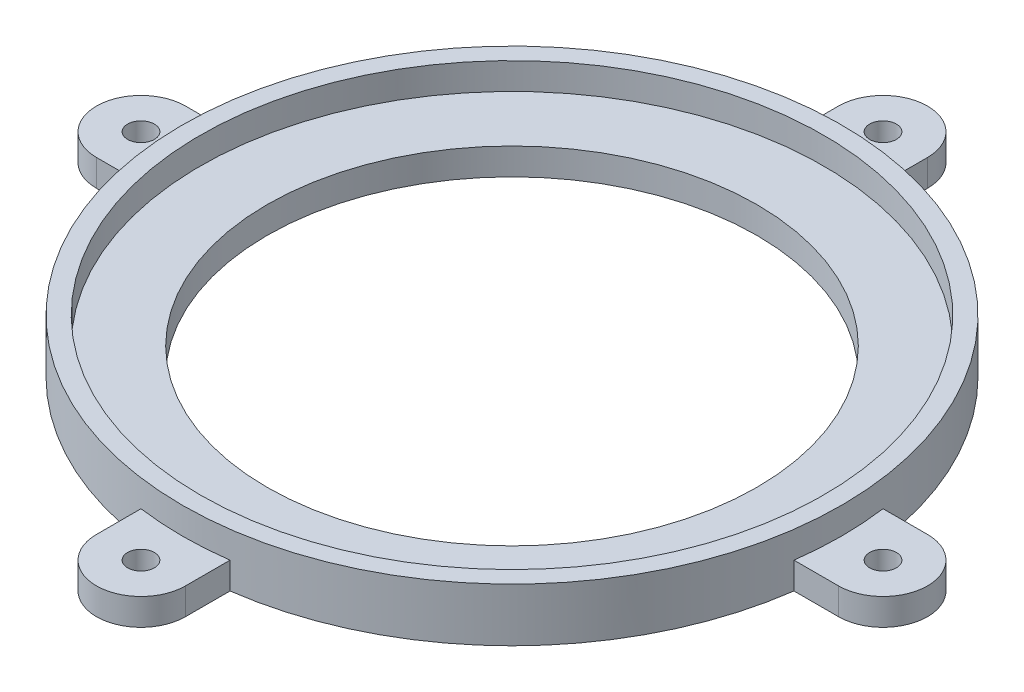
from build123d import *

# Parameters (mm, degrees)
SKETCH1_R           = 1.905
BOSS_EXTRUDE1_DEPTH = 3.81
SKETCH2_R           = 34.925
CUT_EXTRUDE2_DEPTH  = 4.81
SKETCH3_R           = 46.99
SKETCH3_R_2         = 44.45
BOSS_EXTRUDE2_DEPTH = 3.81


with BuildPart() as part:
    # Sketch1 → Boss-Extrude1 (new body)
    with BuildSketch(Plane(origin=(0, 0, 0), x_dir=(1, 0, 0), z_dir=(0, 1, 0))):
        with BuildLine():
            Line((46.558969061, 6.35), (52.908969061, 6.35))
            ThreePointArc((52.908969061, 6.35), (59.258969061, 0), (52.908969061, -6.35))
            Line((52.908969061, -6.35), (46.558969061, -6.35))
            ThreePointArc((46.558969061, -6.35), (33.226947648, -33.226947648), (6.35, -46.558969061))
            Line((6.35, -46.558969061), (6.35, -52.908969061))
            ThreePointArc((6.35, -52.908969061), (0, -59.258969061), (-6.35, -52.908969061))
            Line((-6.35, -52.908969061), (-6.35, -46.558969061))
            ThreePointArc((-6.35, -46.558969061), (-33.226947648, -33.226947648), (-46.558969061, -6.35))
            Line((-46.558969061, -6.35), (-52.908969061, -6.35))
            ThreePointArc((-52.908969061, -6.35), (-59.258969061, 0), (-52.908969061, 6.35))
            Line((-52.908969061, 6.35), (-46.558969061, 6.35))
            ThreePointArc((-46.558969061, 6.35), (-33.226947648, 33.226947648), (-6.35, 46.558969061))
            Line((-6.35, 46.558969061), (-6.35, 52.908969061))
            ThreePointArc((-6.35, 52.908969061), (0, 59.258969061), (6.35, 52.908969061))
            Line((6.35, 52.908969061), (6.35, 46.558969061))
            ThreePointArc((6.35, 46.558969061), (33.226947648, 33.226947648), (46.558969061, 6.35))
        make_face()
        with Locations((52.908969061, 0)):
            Circle(SKETCH1_R, mode=Mode.SUBTRACT)
        with Locations((0, -52.908969061)):
            Circle(SKETCH1_R, mode=Mode.SUBTRACT)
        with Locations((-52.908969061, 0)):
            Circle(SKETCH1_R, mode=Mode.SUBTRACT)
        with Locations((0, 52.908969061)):
            Circle(SKETCH1_R, mode=Mode.SUBTRACT)
    extrude(amount=BOSS_EXTRUDE1_DEPTH)

    # Sketch2 → Cut-Extrude2 (cut, through all)
    with BuildSketch(Plane(origin=(0, 3.81, 0), x_dir=(1, 0, 0), z_dir=(0, 1, 0))):
        Circle(SKETCH2_R)
    extrude(amount=-CUT_EXTRUDE2_DEPTH, mode=Mode.SUBTRACT)

    # Sketch3 → Boss-Extrude2 (add)
    with BuildSketch(Plane(origin=(0, 3.81, 0), x_dir=(1, 0, 0), z_dir=(0, 1, 0))):
        Circle(SKETCH3_R)
        Circle(SKETCH3_R_2, mode=Mode.SUBTRACT)
    extrude(amount=BOSS_EXTRUDE2_DEPTH)


solid = part.part
